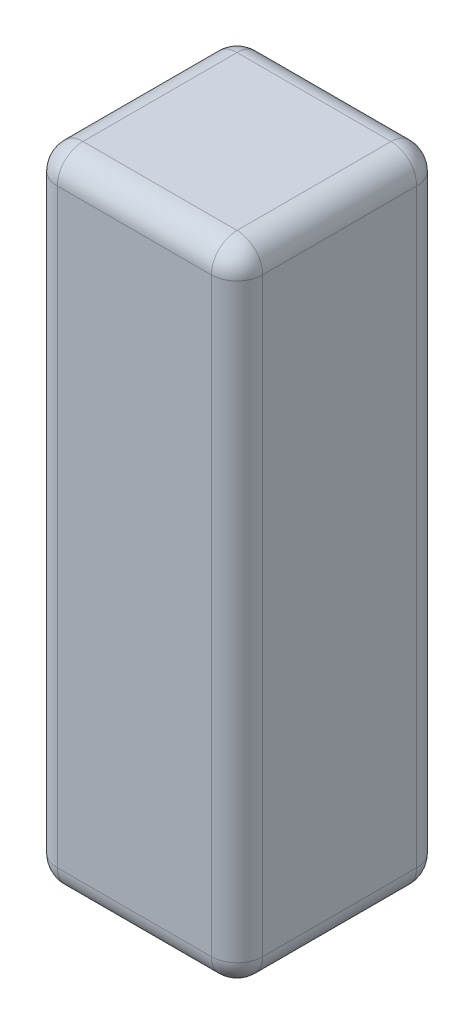
from build123d import *

# Parameters (mm, degrees)
SKETCH1_W           = 32
SKETCH1_H           = 100
BOSS_EXTRUDE1_DEPTH = 32
FILLET1_R           = 4


with BuildPart() as part:
    # Sketch1 → Boss-Extrude1 (new body)
    with BuildSketch(Plane.XY):
        with Locations((68.585871194, -163.776616404)):
            Rectangle(SKETCH1_W, SKETCH1_H)
    extrude(amount=-BOSS_EXTRUDE1_DEPTH)

    # Fillet1
    fillet1_edges = [part.edges().sort_by_distance(p)[0] for p in [
        (84.585871194, -163.776616404, -32),
        (68.585871194, -113.776616404, -32),
        (52.585871194, -163.776616404, -32),
        (68.585871194, -113.776616404, 0),
        (84.585871194, -163.776616404, 0),
        (68.585871194, -213.776616404, 0),
        (52.585871194, -163.776616404, 0),
        (68.585871194, -213.776616404, -32),
        (52.585871194, -113.776616404, -16),
        (84.585871194, -113.776616404, -16),
        (84.585871194, -213.776616404, -16),
        (52.585871194, -213.776616404, -16),
    ]]
    fillet(fillet1_edges, radius=FILLET1_R)


solid = part.part
